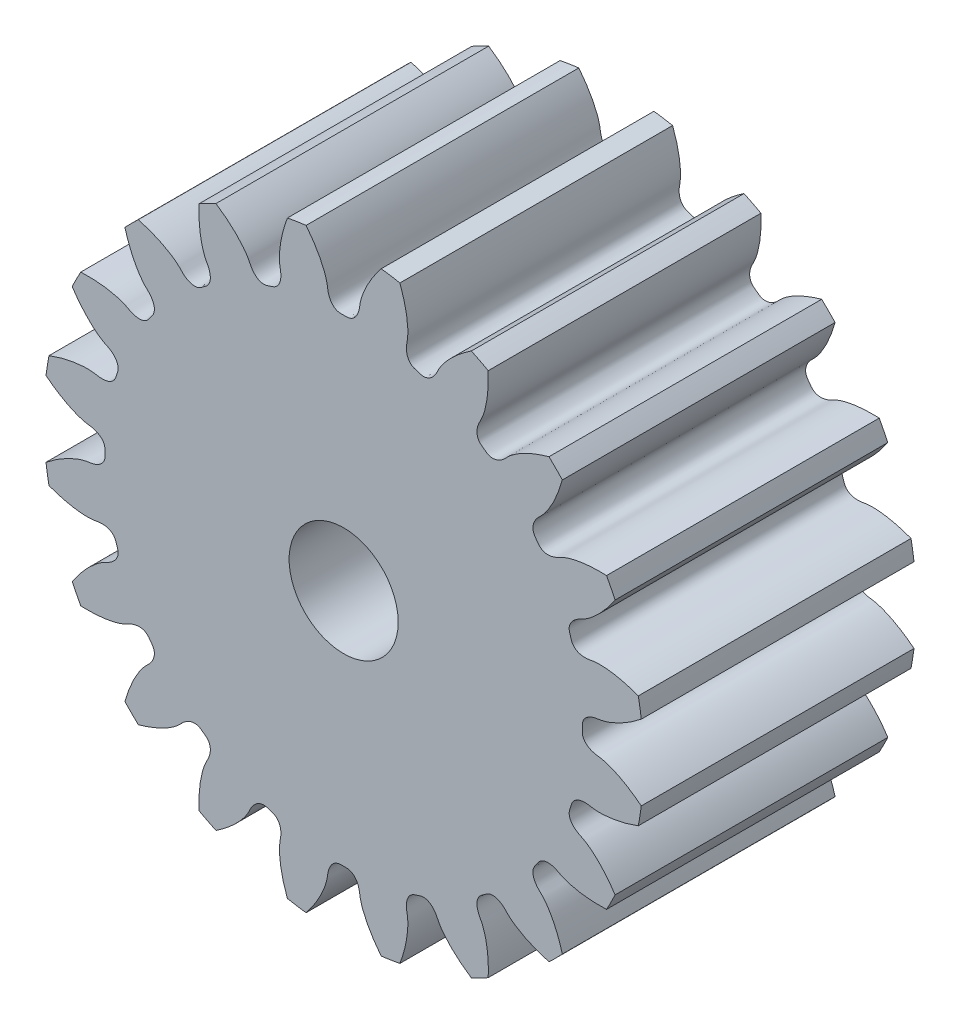
from build123d import *

# Parameters (mm, degrees)
SKETCHREVOLVESPURGEAR1_W       = 5
SKETCHREVOLVESPURGEAR1_H       = 5.499999917
TOOTHEXTRUDECUTSPURGEAR1_DEPTH = 2.5
PATTERNSPURGEAR1_COUNT         = 20
BOREREVOLVESKETCH_W            = 5
BOREREVOLVESKETCH_H            = 1


with BuildPart() as part:
    # SketchRevolveSpurGear1 → SpurGear1 (revolve)
    with BuildSketch(Plane(origin=(0, 0, 0), x_dir=(0, 0, -1), z_dir=(1, 0, 0))):
        with Locations((0, 2.749999959)):
            Rectangle(SKETCHREVOLVESPURGEAR1_W, SKETCHREVOLVESPURGEAR1_H)
    revolve(axis=Axis((0, 0, 0), (0, 0, -1)))

    # SketchToothSpurGear1 → ToothExtrudeCutSpurGear1 (cut, symmetric)
    with BuildSketch(Plane.XY):
        with BuildLine():
            ThreePointArc((5.479605309, 0.706788324), (5.524999917, 0), (5.479605309, -0.706788324))
            add(Edge.make_bspline(
                [(5.479605309, -0.706788324), (5.435404482, -0.670877372), (5.369307557, -0.620309878), (5.280568529, -0.558889651), (5.218284655, -0.51856898), (5.158633122, -0.482517921), (5.101814762, -0.450532909), (5.048020267, -0.422402065), (4.997429872, -0.397905741), (4.950213056, -0.376816955), (4.906528269, -0.3589018), (4.866522656, -0.343920086), (4.830331878, -0.331625257), (4.79807968, -0.321766639), (4.769878333, -0.31408451), (4.745826516, -0.308326896), (4.726014734, -0.304202955), (4.6830745, -0.296753707), (4.637427165, -0.292743909), (4.589884099, -0.280886123), (4.565199786, -0.273548043), (4.541459249, -0.264988916), (4.518564058, -0.255118714), (4.496419545, -0.243708294), (4.474943599, -0.230444344), (4.454110549, -0.214878544), (4.434031507, -0.196415078), (4.415082677, -0.174339712), (4.398103211, -0.147959142), (4.384426421, -0.116954775), (4.376754303, -0.084451556), (4.373607289, -0.044989712), (4.375891317, 0), (4.373607289, 0.044989712), (4.376754303, 0.084451556), (4.384426421, 0.116954775), (4.398103211, 0.147959142), (4.415082677, 0.174339712), (4.434031507, 0.196415078), (4.454110549, 0.214878544), (4.474943599, 0.230444344), (4.496419545, 0.243708294), (4.518564058, 0.255118714), (4.541459249, 0.264988916), (4.565199786, 0.273548043), (4.589884099, 0.280886123), (4.637427165, 0.292743909), (4.6830745, 0.296753707), (4.726014734, 0.304202955), (4.745826516, 0.308326896), (4.769878333, 0.31408451), (4.79807968, 0.321766639), (4.830331878, 0.331625257), (4.866522656, 0.343920086), (4.906528269, 0.3589018), (4.950213056, 0.376816955), (4.997429872, 0.397905741), (5.048020267, 0.422402065), (5.101814762, 0.450532909), (5.158633122, 0.482517921), (5.218284655, 0.51856898), (5.280568529, 0.558889651), (5.369307557, 0.620309878), (5.435404482, 0.670877372), (5.479605309, 0.706788324)],
                knots=[0, 0, 0, 0, 0.061422842, 0.089709677, 0.116380121, 0.141434175, 0.164871838, 0.186693111, 0.206897994, 0.225486485, 0.242458587, 0.257814298, 0.271553618, 0.283676548, 0.294183087, 0.303073236, 0.310346995, 0.316004363, 0.350076802, 0.359567688, 0.36880314, 0.37784437, 0.386769007, 0.395675631, 0.404688756, 0.413962948, 0.423682731, 0.434051196, 0.445255861, 0.457401439, 0.47041984, 0.481066796, 0.5, 0.518933204, 0.52958016, 0.542598561, 0.554744139, 0.565948804, 0.576317269, 0.586037052, 0.595311244, 0.604324369, 0.613230993, 0.62215563, 0.63119686, 0.640432312, 0.649923198, 0.683995637, 0.689653005, 0.696926764, 0.705816913, 0.716323452, 0.728446382, 0.742185702, 0.757541413, 0.774513515, 0.793102006, 0.813306889, 0.835128162, 0.858565825, 0.883619879, 0.910290323, 0.938577158, 1, 1, 1, 1], degree=3))
        make_face()
    toothextrudecutspurgear1 = extrude(amount=TOOTHEXTRUDECUTSPURGEAR1_DEPTH, both=True, mode=Mode.SUBTRACT)

    # PatternSpurGear1: ToothExtrudeCutSpurGear1 ×20 about axis
    patternspurgear1_axis = Axis((0, 0, 55), (0, 0, -1))
    for i in range(1, PATTERNSPURGEAR1_COUNT):
        add(toothextrudecutspurgear1.rotate(patternspurgear1_axis, i * 360 / PATTERNSPURGEAR1_COUNT), mode=Mode.SUBTRACT)

    # BoreRevolveSketch → BoreRevolveCut (revolve, cut)
    with BuildSketch(Plane(origin=(0, 0, 0), x_dir=(0, 0, -1), z_dir=(1, 0, 0))):
        with Locations((0, 0.5)):
            Rectangle(BOREREVOLVESKETCH_W, BOREREVOLVESKETCH_H)
    revolve(axis=Axis((0, 0, 0), (0, 0, -1)), mode=Mode.SUBTRACT)


solid = part.part
